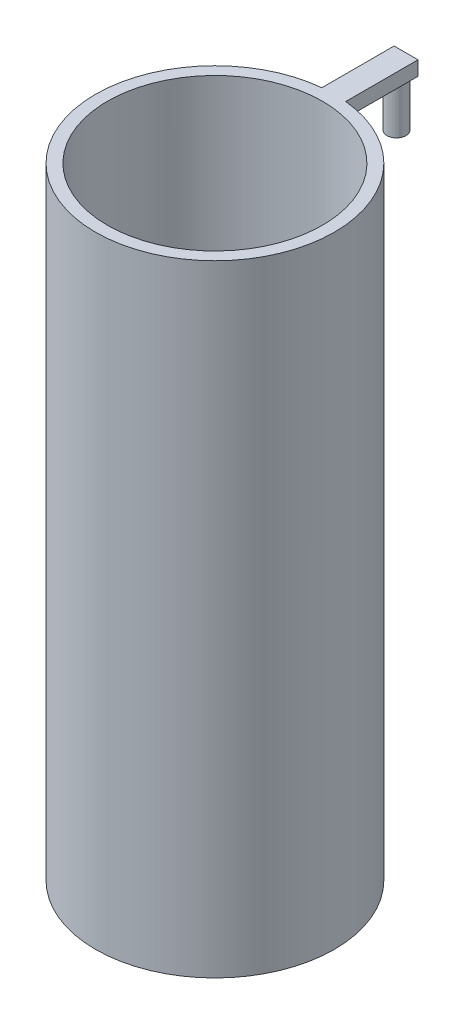
from build123d import *

# Parameters (mm, degrees)
SKETCH1_R           = 25
SKETCH1_R_2         = 22.5
BOSS_EXTRUDE1_DEPTH = 130
SKETCH2_R           = 25
BOSS_EXTRUDE2_DEPTH = 5
BOSS_EXTRUDE3_DEPTH = 3
SKETCH4_R           = 2
BOSS_EXTRUDE4_DEPTH = 10


with BuildPart() as part:
    # Sketch1 → Boss-Extrude1 (new body)
    with BuildSketch(Plane(origin=(0, 0, 0), x_dir=(1, 0, 0), z_dir=(0, 1, 0))):
        Circle(SKETCH1_R)
        Circle(SKETCH1_R_2, mode=Mode.SUBTRACT)
    extrude(amount=BOSS_EXTRUDE1_DEPTH)

    # Sketch2 → Boss-Extrude2 (add)
    with BuildSketch(Plane.XZ):
        Circle(SKETCH2_R)
    extrude(amount=-BOSS_EXTRUDE2_DEPTH)

    # Sketch3 → Boss-Extrude3 (add)
    with BuildSketch(Plane(origin=(0, 130, 0), x_dir=(1, 0, 0), z_dir=(0, 1, 0))):
        with BuildLine():
            ThreePointArc((-2.5, 24.874685928), (-1.251569376, 24.968651828), (0, 25))
            Line((0, 25), (0, 40))
            Line((0, 40), (-2.5, 40))
            Line((-2.5, 40), (-2.5, 24.874685928))
        make_face()
        with BuildLine():
            Line((0, 40), (0, 25))
            ThreePointArc((0, 25), (1.251569376, 24.968651828), (2.5, 24.874685928))
            Line((2.5, 24.874685928), (2.5, 40))
            Line((2.5, 40), (0, 40))
        make_face()
    extrude(amount=-BOSS_EXTRUDE3_DEPTH)

    # Sketch4 → Boss-Extrude4 (add)
    with BuildSketch(Plane.XZ.offset(-127)):
        with Locations((0, -38)):
            Circle(SKETCH4_R)
    extrude(amount=BOSS_EXTRUDE4_DEPTH)


solid = part.part
